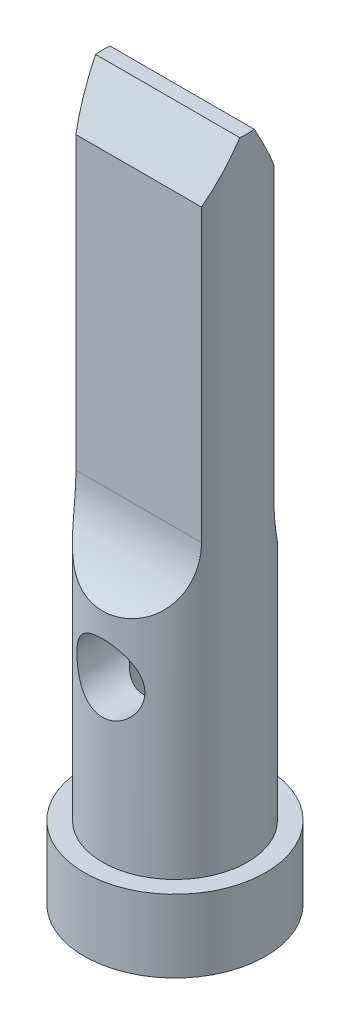
from build123d import *

# Parameters (mm, degrees)
F_4_40_TAPPED_HOLE1_D           = 2.2606
F_4_40_TAPPED_HOLE1_DEPTH       = 8.763
F_4_40_TAPPED_HOLE1_CSINK_D     = 3.302
F_4_40_TAPPED_HOLE1_CSINK_ANGLE = 82
F_4_40_TAPPED_HOLE1_TIP         = 0.679152758
F_3_32_0_09375_DIAMETER_HOLE1_D = 2.38125
CUT_EXTRUDE1_DEPTH              = 26.043807596
CIRPATTERN1_COUNT               = 2
CHAMFER1_SIZE                   = 1.016
CHAMFER1_SIZE2                  = 1.75976362


with BuildPart() as part:
    # Sketch1 → Revolve1 (revolve)
    with BuildSketch(Plane.XY, mode=Mode.PRIVATE) as revolve1_sk:
        Polygon((0, 0), (3.175, 0), (3.175, 2.54), (2.54, 2.54), (2.54, 24.638), (0, 24.638), align=None)
    revolve(revolve1_sk.sketch.rotate(Axis((0, 0, 0), (0, 1, 0)), 90), axis=Axis((0, 0, 0), (0, 1, 0)))

    # 4-40 Tapped Hole1
    with Locations(Plane.XZ):
        with Locations((0, 0)):
            CounterSinkHole(F_4_40_TAPPED_HOLE1_D / 2, F_4_40_TAPPED_HOLE1_CSINK_D / 2, depth=F_4_40_TAPPED_HOLE1_DEPTH, counter_sink_angle=F_4_40_TAPPED_HOLE1_CSINK_ANGLE)
            with Locations((0, 0, -(F_4_40_TAPPED_HOLE1_DEPTH + F_4_40_TAPPED_HOLE1_TIP / 2))):  # 118° drill point
                Cone(0, F_4_40_TAPPED_HOLE1_D / 2, F_4_40_TAPPED_HOLE1_TIP, mode=Mode.SUBTRACT)

    # 3_32 _0.09375_ Diameter Hole1 (through all)
    with Locations(Plane.XY.offset(2.54)):
        with Locations((0, 8.128)):
            Hole(F_3_32_0_09375_DIAMETER_HOLE1_D / 2)

    # Sketch6 → Cut-Extrude1 (cut, symmetric)
    with BuildSketch(Plane(origin=(0, 0, 0), x_dir=(0, 0, -1), z_dir=(1, 0, 0))):
        with BuildLine():
            Line((1.27, 24.638), (1.27, 12.7))
            ThreePointArc((1.27, 12.7), (1.605193669, 11.280096834), (2.54, 10.16))
            Line((2.54, 10.16), (2.54, 24.638))
            Line((2.54, 24.638), (1.27, 24.638))
        make_face()
    cut_extrude1 = extrude(amount=CUT_EXTRUDE1_DEPTH, both=True, mode=Mode.SUBTRACT)

    # CirPattern1: Cut-Extrude1 ×2 about axis
    cirpattern1_axis = Axis((0, -1.2319, 0), (0, 1, 0))
    for i in range(1, CIRPATTERN1_COUNT):
        add(cut_extrude1.rotate(cirpattern1_axis, i * 360 / CIRPATTERN1_COUNT), mode=Mode.SUBTRACT)

    # Chamfer1
    chamfer1_edges = [part.edges().sort_by_distance(p)[0] for p in [
        (0, 24.638, -1.27),
        (0, 24.638, 1.27),
    ]]
    chamfer1_side = [part.faces().sort_by_distance(p)[0] for p in [
        (0, 24.638, 0),
    ]]
    chamfer(chamfer1_edges, length=CHAMFER1_SIZE, length2=CHAMFER1_SIZE2, reference=chamfer1_side[0])


solid = part.part
